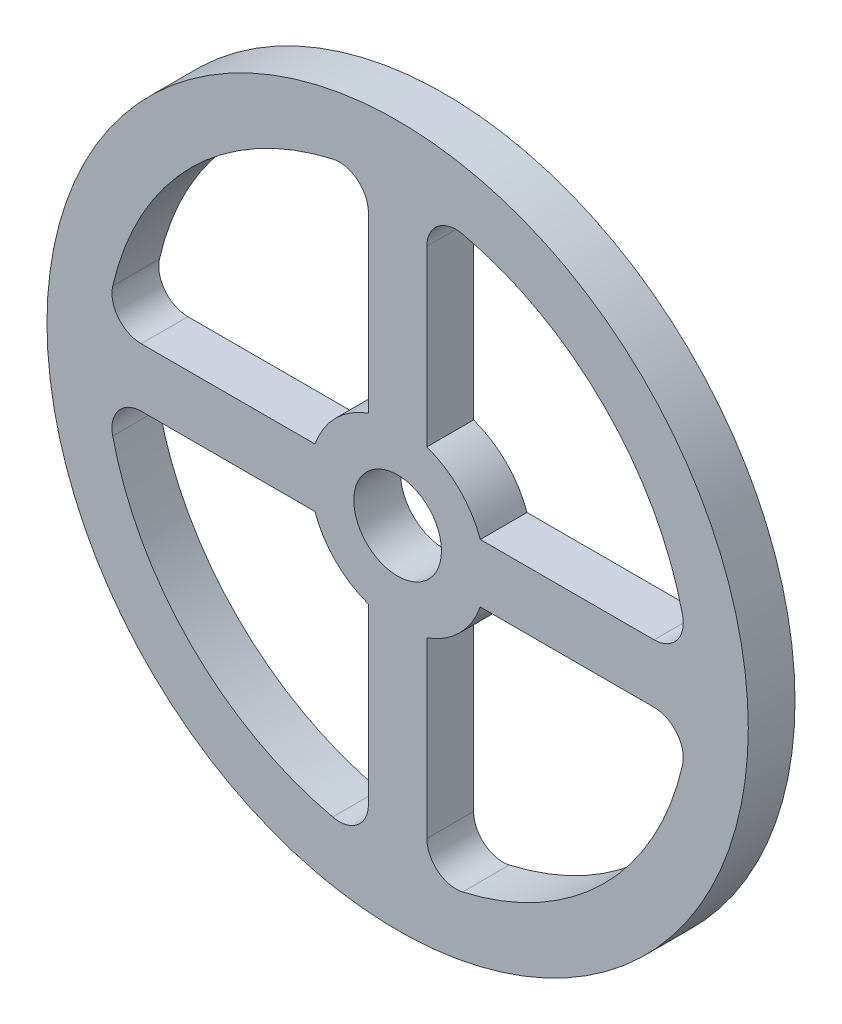
from build123d import *

# Parameters (mm, degrees)
SKETCH1_R           = 120
SKETCH1_R_2         = 15
BOSS_EXTRUDE1_DEPTH = 16


with BuildPart() as part:
    # Sketch1 → Boss-Extrude1 (new body)
    with BuildSketch(Plane.XY):
        with Locations((-157.313413121, 131.73738084)):
            Circle(SKETCH1_R)
        with Locations((-157.313413121, 131.73738084)):
            Circle(SKETCH1_R_2, mode=Mode.SUBTRACT)
        with BuildLine():
            Line((-167.313413121, 103.453109593), (-167.313413121, 43.987736967))
            ThreePointArc((-167.313413121, 43.987736967), (-171.077317476, 36.170377367), (-179.535635343, 34.237776536))
            ThreePointArc((-179.535635343, 34.237776536), (-228.024091239, 61.026702722), (-254.813017425, 109.515158618))
            ThreePointArc((-254.813017425, 109.515158618), (-252.880416594, 117.973476485), (-245.063056995, 121.73738084))
            Line((-245.063056995, 121.73738084), (-185.597684368, 121.73738084))
            ThreePointArc((-185.597684368, 121.73738084), (-178.526616556, 110.524177405), (-167.313413121, 103.453109593))
        make_face(mode=Mode.SUBTRACT)
        with BuildLine():
            Line((-245.063056995, 141.73738084), (-185.597684368, 141.73738084))
            ThreePointArc((-185.597684368, 141.73738084), (-178.526616556, 152.950584276), (-167.313413121, 160.021652088))
            Line((-167.313413121, 160.021652088), (-167.313413121, 219.487024714))
            ThreePointArc((-167.313413121, 219.487024714), (-171.077317476, 227.304384314), (-179.535635343, 229.236985145))
            ThreePointArc((-179.535635343, 229.236985145), (-228.024091239, 202.448058959), (-254.813017425, 153.959603063))
            ThreePointArc((-254.813017425, 153.959603063), (-252.880416594, 145.501285196), (-245.063056995, 141.73738084))
        make_face(mode=Mode.SUBTRACT)
        with BuildLine():
            Line((-147.313413121, 219.487024714), (-147.313413121, 160.021652088))
            ThreePointArc((-147.313413121, 160.021652088), (-136.100209685, 152.950584276), (-129.029141873, 141.73738084))
            Line((-129.029141873, 141.73738084), (-69.563769247, 141.73738084))
            ThreePointArc((-69.563769247, 141.73738084), (-61.746409647, 145.501285196), (-59.813808816, 153.959603063))
            ThreePointArc((-59.813808816, 153.959603063), (-86.602735002, 202.448058959), (-135.091190899, 229.236985145))
            ThreePointArc((-135.091190899, 229.236985145), (-143.549508765, 227.304384314), (-147.313413121, 219.487024714))
        make_face(mode=Mode.SUBTRACT)
        with BuildLine():
            Line((-147.313413121, 103.453109593), (-147.313413121, 43.987736967))
            ThreePointArc((-147.313413121, 43.987736967), (-143.549508765, 36.170377367), (-135.091190899, 34.237776536))
            ThreePointArc((-135.091190899, 34.237776536), (-86.602735002, 61.026702722), (-59.813808816, 109.515158618))
            ThreePointArc((-59.813808816, 109.515158618), (-61.746409647, 117.973476485), (-69.563769247, 121.73738084))
            Line((-69.563769247, 121.73738084), (-129.029141873, 121.73738084))
            ThreePointArc((-129.029141873, 121.73738084), (-136.100209685, 110.524177405), (-147.313413121, 103.453109593))
        make_face(mode=Mode.SUBTRACT)
    extrude(amount=BOSS_EXTRUDE1_DEPTH)


solid = part.part
